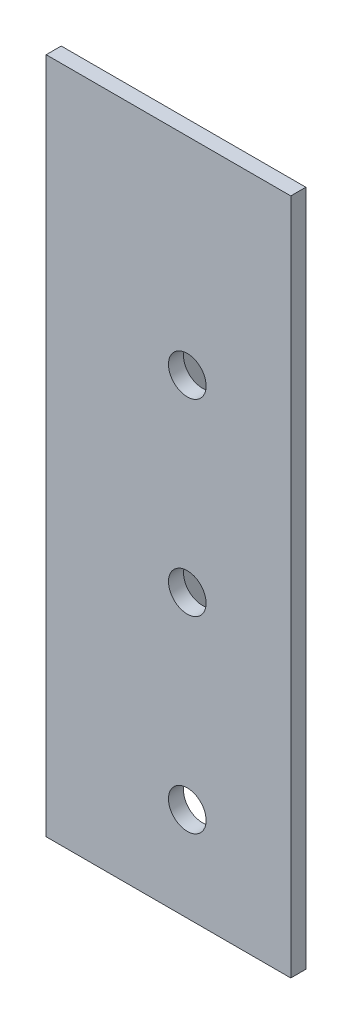
from build123d import *

# Parameters (mm, degrees)
EXTRUDE_1_DEPTH     = 180
SKETCH_6_R          = 5
CUT_EXTRUDE_1_DEPTH = 10
CUT_EXTRUDE_2_DEPTH = 10


with BuildPart() as part:
    # Эскиз1 → Вытянуть-Тонкостенный1 (new body)
    with BuildSketch(Plane(origin=(0, 0, 0), x_dir=(1, 0, 0), z_dir=(0, 1, 0))):
        Polygon((0, 65), (0, 0), (65, 0), (65, 4), (4, 4), (4, 65), align=None)
    extrude(amount=EXTRUDE_1_DEPTH)

    # Эскиз6 → Вырез-Вытянуть1 (cut)
    with BuildSketch(Plane(origin=(0, 0, 0), x_dir=(-1, 0, 0), z_dir=(0, 0, -1))):
        with Locations((-37.5, 25)):
            Circle(SKETCH_6_R)
        with Locations((-37.5, 75)):
            Circle(SKETCH_6_R)
        with Locations((-37.5, 125)):
            Circle(SKETCH_6_R)
    extrude(amount=CUT_EXTRUDE_1_DEPTH, mode=Mode.SUBTRACT)

    # Эскиз9 → Вырез-Вытянуть2 (cut)
    with BuildSketch(Plane.ZY):
        Polygon((-4, 180), (-65, 180), (-65, 119), align=None)
    extrude(amount=-CUT_EXTRUDE_2_DEPTH, mode=Mode.SUBTRACT)


solid = part.part
